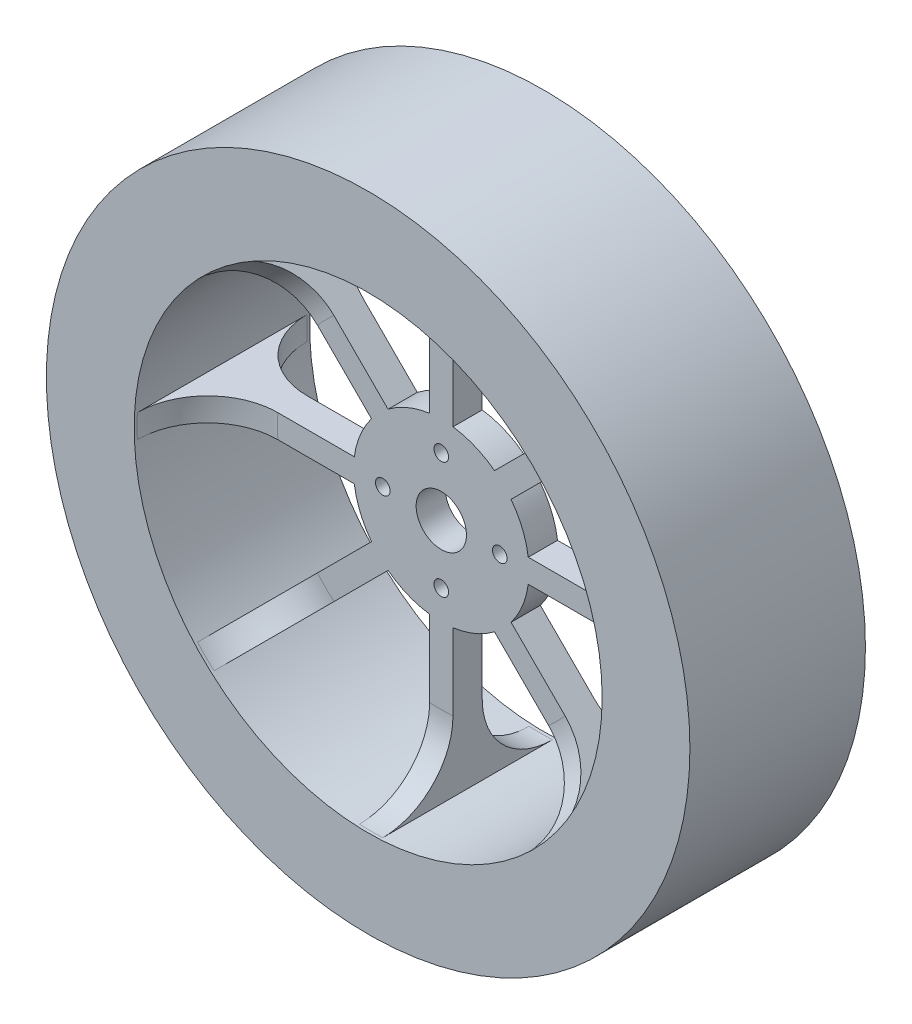
from build123d import *

# Parameters (mm, degrees)
CROQUIS1_R              = 1.25
SALIENTE_EXTRUIR1_DEPTH = 2.5
CROQUIS2_R              = 55
CROQUIS2_R_2            = 40
SALIENTE_EXTRUIR3_DEPTH = 15
REDONDEO1_R             = 12
CROQUIS3_R              = 15
CROQUIS3_R_2            = 1.35
SALIENTE_EXTRUIR5_DEPTH = 5
CROQUIS4_R              = 4.3
CORTAR_EXTRUIR1_DEPTH   = 5


with BuildPart() as part:
    # Croquis1 → Saliente-Extruir1 (new body, symmetric)
    with BuildSketch(Plane.XY):
        with BuildLine():
            Line((-2, 44.955533586), (-2, 7.228416147))
            ThreePointArc((-2, 7.228416147), (-2.870125743, 6.929096494), (-3.697048513, 6.525475637))
            Line((-3.697048513, 6.525475637), (-30.374149088, 33.202576213))
            ThreePointArc((-30.374149088, 33.202576213), (-31.819805153, 31.819805153), (-33.202576213, 30.374149088))
            Line((-33.202576213, 30.374149088), (-6.525475637, 3.697048513))
            ThreePointArc((-6.525475637, 3.697048513), (-6.929096494, 2.870125743), (-7.228416147, 2))
            Line((-7.228416147, 2), (-44.955533586, 2))
            ThreePointArc((-44.955533586, 2), (-45, 0), (-44.955533586, -2))
            Line((-44.955533586, -2), (-7.228416147, -2))
            ThreePointArc((-7.228416147, -2), (-6.929096494, -2.870125743), (-6.525475637, -3.697048513))
            Line((-6.525475637, -3.697048513), (-33.202576213, -30.374149088))
            ThreePointArc((-33.202576213, -30.374149088), (-31.819805153, -31.819805153), (-30.374149088, -33.202576213))
            Line((-30.374149088, -33.202576213), (-3.697048513, -6.525475637))
            ThreePointArc((-3.697048513, -6.525475637), (-2.870125743, -6.929096494), (-2, -7.228416147))
            Line((-2, -7.228416147), (-2, -44.955533586))
            ThreePointArc((-2, -44.955533586), (0, -45), (2, -44.955533586))
            Line((2, -44.955533586), (2, -7.228416147))
            ThreePointArc((2, -7.228416147), (2.870125743, -6.929096494), (3.697048513, -6.525475637))
            Line((3.697048513, -6.525475637), (30.374149088, -33.202576213))
            ThreePointArc((30.374149088, -33.202576213), (31.819805153, -31.819805153), (33.202576213, -30.374149088))
            Line((33.202576213, -30.374149088), (6.525475637, -3.697048513))
            ThreePointArc((6.525475637, -3.697048513), (6.929096494, -2.870125743), (7.228416147, -2))
            Line((7.228416147, -2), (44.955533586, -2))
            ThreePointArc((44.955533586, -2), (44.988882023, -1.000247127), (45, 0))
            ThreePointArc((45, 0), (44.988882023, 1.000247127), (44.955533586, 2))
            Line((44.955533586, 2), (7.228416147, 2))
            ThreePointArc((7.228416147, 2), (6.929096494, 2.870125743), (6.525475637, 3.697048513))
            Line((6.525475637, 3.697048513), (33.202576213, 30.374149088))
            ThreePointArc((33.202576213, 30.374149088), (31.819805153, 31.819805153), (30.374149088, 33.202576213))
            Line((30.374149088, 33.202576213), (3.697048513, 6.525475637))
            ThreePointArc((3.697048513, 6.525475637), (2.870125743, 6.929096494), (2, 7.228416147))
            Line((2, 7.228416147), (2, 44.955533586))
            ThreePointArc((2, 44.955533586), (0, 45), (-2, 44.955533586))
        make_face()
        with Locations((0, -10)):
            Circle(CROQUIS1_R, mode=Mode.SUBTRACT)
        with Locations((-10, 0)):
            Circle(CROQUIS1_R, mode=Mode.SUBTRACT)
        with Locations((10, 0)):
            Circle(CROQUIS1_R, mode=Mode.SUBTRACT)
        with Locations((0, 10)):
            Circle(CROQUIS1_R, mode=Mode.SUBTRACT)
    extrude(amount=SALIENTE_EXTRUIR1_DEPTH, both=True)

    # Croquis2 → Saliente-Extruir3 (add, symmetric)
    with BuildSketch(Plane.XY):
        Circle(CROQUIS2_R)
        Circle(CROQUIS2_R_2, mode=Mode.SUBTRACT)
    extrude(amount=SALIENTE_EXTRUIR3_DEPTH, both=True)

    # Redondeo1
    redondeo1_edges = [part.edges().sort_by_distance(p)[0] for p in [
        (39.987490222, 1.000312842, -2.5),
        (28.284271247, 28.284271247, -2.5),
        (0, 40, -2.5),
        (-28.284271247, 28.284271247, -2.5),
        (-40, 0, -2.5),
        (-28.284271247, -28.284271247, -2.5),
        (0, -40, -2.5),
        (28.284271247, -28.284271247, -2.5),
        (28.284271247, -28.284271247, 2.5),
        (0, -40, 2.5),
        (-28.284271247, -28.284271247, 2.5),
        (-40, 0, 2.5),
        (-28.284271247, 28.284271247, 2.5),
        (0, 40, 2.5),
        (28.284271247, 28.284271247, 2.5),
        (39.987490222, 1.000312842, 2.5),
    ]]
    fillet(redondeo1_edges, radius=REDONDEO1_R)

    # Croquis3 → Saliente-Extruir5 (add)
    with BuildSketch(Plane(origin=(0, 0, -2.5), x_dir=(-1, 0, 0), z_dir=(0, 0, -1))):
        Circle(CROQUIS3_R)
        with Locations((0, 10)):
            Circle(CROQUIS3_R_2, mode=Mode.SUBTRACT)
        with Locations((10, 0)):
            Circle(CROQUIS3_R_2, mode=Mode.SUBTRACT)
        with Locations((0, -10)):
            Circle(CROQUIS3_R_2, mode=Mode.SUBTRACT)
        with Locations((-10, 0)):
            Circle(CROQUIS3_R_2, mode=Mode.SUBTRACT)
    extrude(amount=-SALIENTE_EXTRUIR5_DEPTH)

    # Croquis4 → Cortar-Extruir1 (cut)
    with BuildSketch(Plane.XY.offset(2.5)):
        Circle(CROQUIS4_R)
    extrude(amount=-CORTAR_EXTRUIR1_DEPTH, mode=Mode.SUBTRACT)


solid = part.part
